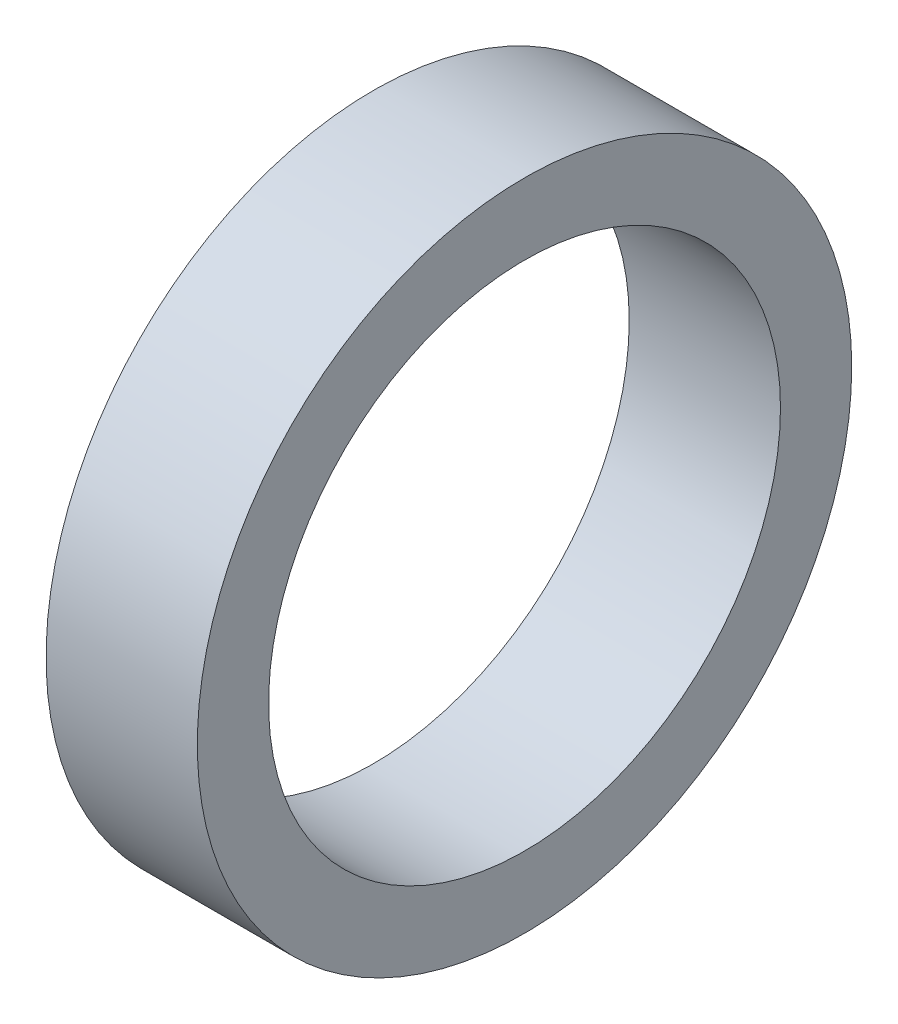
from build123d import *

# Parameters (mm, degrees)
SKETCH1_R           = 14.2875
SKETCH1_R_2         = 11.176
BOSS_EXTRUDE1_DEPTH = 6.604


with BuildPart() as part:
    # Sketch1 → Boss-Extrude1 (new body)
    with BuildSketch(Plane(origin=(0, 0, 0), x_dir=(0, 0, -1), z_dir=(1, 0, 0))):
        Circle(SKETCH1_R)
        Circle(SKETCH1_R_2, mode=Mode.SUBTRACT)
    extrude(amount=BOSS_EXTRUDE1_DEPTH)


solid = part.part
